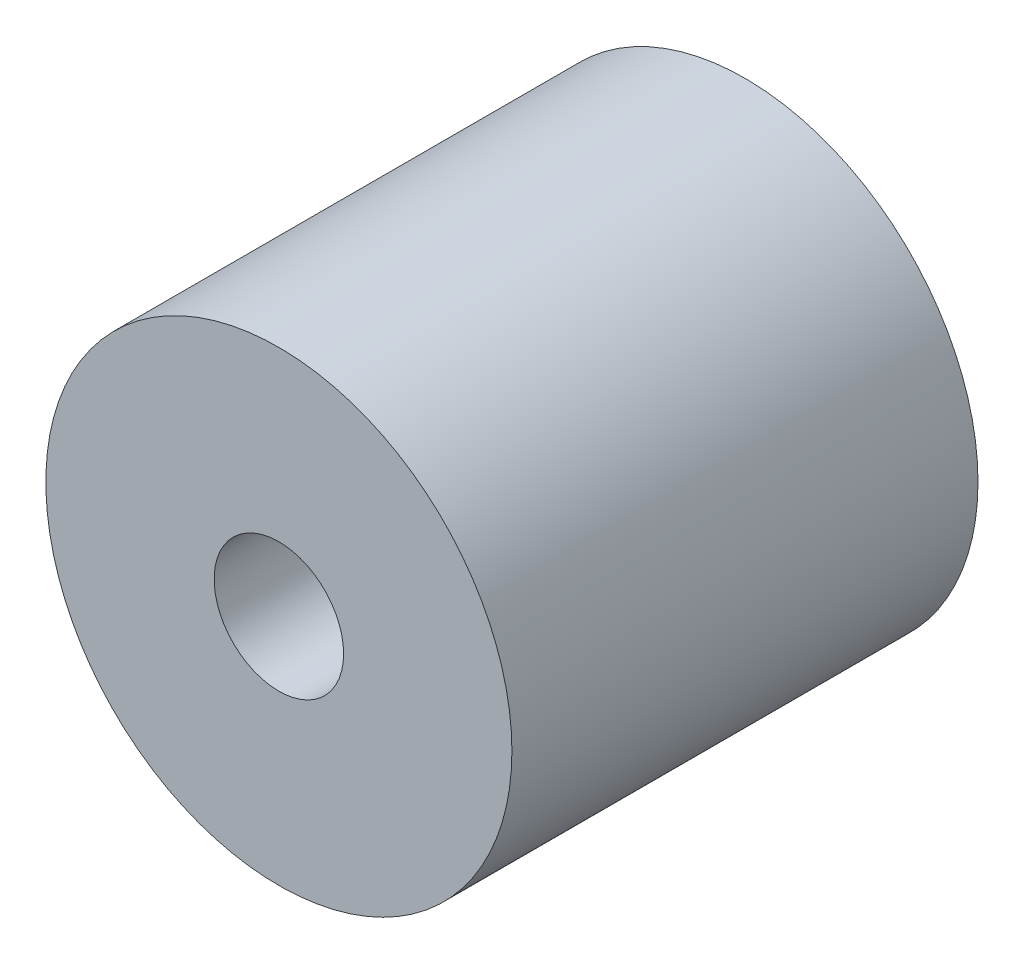
from build123d import *

# Parameters (mm, degrees)
SKETCH_1_R      = 9
SKETCH_1_R_2    = 2.5
EXTRUDE_1_DEPTH = 18


with BuildPart() as part:
    # 草图1 → 凸台-拉伸1 (new body)
    with BuildSketch(Plane.XY):
        with Locations((0.736104657, 4.999377465)):
            Circle(SKETCH_1_R)
        with Locations((0.736104657, 4.999377465)):
            Circle(SKETCH_1_R_2, mode=Mode.SUBTRACT)
    extrude(amount=EXTRUDE_1_DEPTH)


solid = part.part
